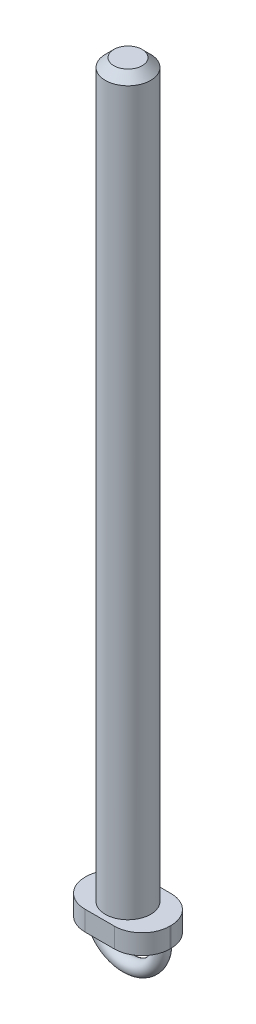
from build123d import *

# Parameters (mm, degrees)
ESBO_O2_R             = 11
CORTE_EXTRUS_O1_DEPTH = 10
ESBO_O7_R             = 1.25
CHANFRO1_SIZE         = 1.5


with BuildPart() as part:
    # Esboço1 → Revolução1 (revolve)
    with BuildSketch(Plane.XY):
        Polygon((0, 0), (11, 0), (11, 3.5), (4, 3.5), (4, 132.66), (0, 132.66), align=None)
    revolve(axis=Axis((0, 132.66, 0), (0, -1, 0)))

    # Esboço2 → Corte-extrusão1 (cut)
    with BuildSketch(Plane.XZ):
        Circle(ESBO_O2_R)
        with BuildLine():
            ThreePointArc((7.5, -0.1), (6.064823228, -3.564823228), (2.6, -5))
            Line((2.6, -5), (-2.6, -5))
            ThreePointArc((-2.6, -5), (-6.064823228, -3.564823228), (-7.5, -0.1))
            Line((-7.5, -0.1), (-7.5, 0.1))
            ThreePointArc((-7.5, 0.1), (-6.064823228, 3.564823228), (-2.6, 5))
            Line((-2.6, 5), (2.6, 5))
            ThreePointArc((2.6, 5), (6.064823228, 3.564823228), (7.5, 0.1))
            Line((7.5, 0.1), (7.5, -0.1))
        make_face(mode=Mode.SUBTRACT)
    extrude(amount=-CORTE_EXTRUS_O1_DEPTH, mode=Mode.SUBTRACT)

    # Varredura1: sweep along a path in Esboço9
    with BuildLine(Plane.XY) as varredura1_path:
        ThreePointArc((-6, 0), (0, -6), (6, 0))
    # Esboço7 → Varredura1 (sweep)
    with BuildSketch(Plane(origin=(0, 0, 0), x_dir=(-1, 0, 0), z_dir=(0, -1, 0))):
        with Locations((6, 0)):
            Circle(ESBO_O7_R)
    sweep(path=varredura1_path.line)

    # Chanfro1
    chanfro1_edges = [part.edges().sort_by_distance(p)[0] for p in [
        (-4, 132.66, 0),
    ]]
    chamfer(chanfro1_edges, length=CHANFRO1_SIZE)


solid = part.part
